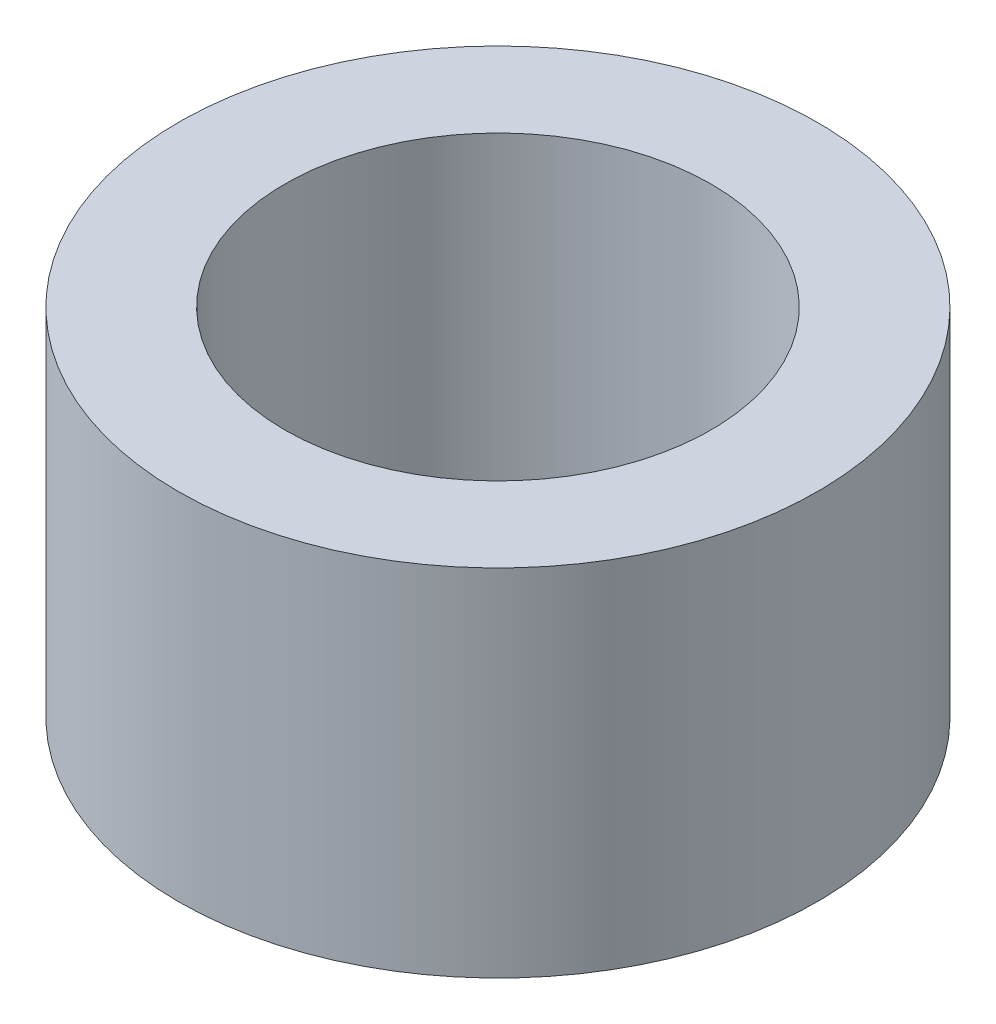
from build123d import *

# Parameters (mm, degrees)
SKETCH1_R           = 9
BOSS_EXTRUDE1_DEPTH = 10
SKETCH2_R           = 6
CUT_EXTRUDE1_DEPTH  = 10


with BuildPart() as part:
    # Sketch1 → Boss-Extrude1 (new body)
    with BuildSketch(Plane(origin=(0, 0, 0), x_dir=(1, 0, 0), z_dir=(0, 1, 0))):
        Circle(SKETCH1_R)
    extrude(amount=BOSS_EXTRUDE1_DEPTH)

    # Sketch2 → Cut-Extrude1 (cut)
    with BuildSketch(Plane(origin=(0, 10, 0), x_dir=(1, 0, 0), z_dir=(0, 1, 0))):
        Circle(SKETCH2_R)
    extrude(amount=-CUT_EXTRUDE1_DEPTH, mode=Mode.SUBTRACT)


solid = part.part
